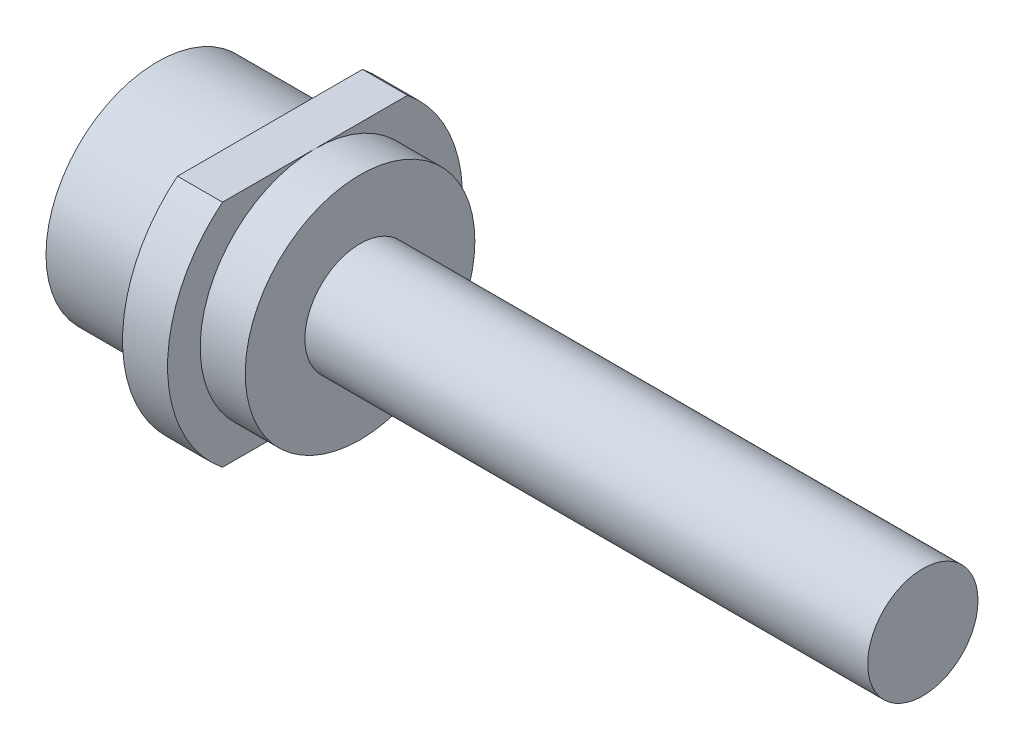
from build123d import *

# Parameters (mm, degrees)
EXTRUDE_1_DEPTH = 2
SKETCH_3_R      = 5.1
EXTRUDE_2_DEPTH = 2
SKETCH_4_R      = 2.45
EXTRUDE_3_DEPTH = 25
SKETCH_5_R      = 4.95
EXTRUDE_4_DEPTH = 5


with BuildPart() as part:
    # 草图2 → 凸台-拉伸1 (new body)
    with BuildSketch(Plane(origin=(0, 0, 0), x_dir=(0, 0, -1), z_dir=(1, 0, 0))):
        with BuildLine():
            Line((4.110048662, 5.1), (-4.110048662, 5.1))
            ThreePointArc((-4.110048662, 5.1), (-6.55, 0), (-4.110048662, -5.1))
            Line((-4.110048662, -5.1), (4.110048662, -5.1))
            ThreePointArc((4.110048662, -5.1), (6.55, 0), (4.110048662, 5.1))
        make_face()
    extrude(amount=EXTRUDE_1_DEPTH)

    # 草图3 → 凸台-拉伸2 (add)
    with BuildSketch(Plane(origin=(2, 0, 0), x_dir=(0, 0, -1), z_dir=(1, 0, 0))):
        Circle(SKETCH_3_R)
    extrude(amount=EXTRUDE_2_DEPTH)

    # 草图4 → 凸台-拉伸3 (add)
    with BuildSketch(Plane(origin=(4, 0, 0), x_dir=(0, 0, -1), z_dir=(1, 0, 0))):
        Circle(SKETCH_4_R)
    extrude(amount=EXTRUDE_3_DEPTH)

    # 草图5 → 凸台-拉伸4 (add)
    with BuildSketch(Plane.ZY):
        Circle(SKETCH_5_R)
    extrude(amount=EXTRUDE_4_DEPTH)


solid = part.part
